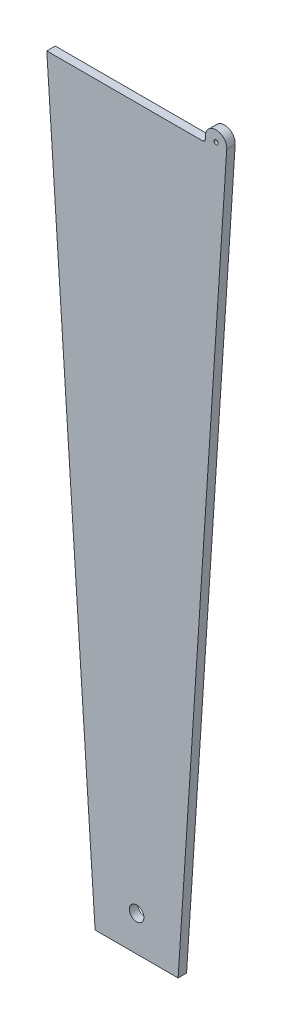
from build123d import *

# Parameters (mm, degrees)
EXTRUDE1_DEPTH     = 1.56
SKETCH2_R          = 1.3462
CUT_EXTRUDE2_DEPTH = 2.56
EXTRUDE2_DEPTH     = 1.56
FILLET1_R          = 0.5
SKETCH5_R          = 0.396875
EXTRUDE3_DEPTH     = 2.56


with BuildPart() as part:
    # Sketch1 → Extrude1 (new body)
    with BuildSketch(Plane.XY):
        Polygon((-7.655500537, 35), (7.655500537, 35), (16.56941148, 171), (-16.56941148, 171), align=None)
    extrude(amount=EXTRUDE1_DEPTH)

    # Sketch2 → Cut-Extrude2 (cut, through all)
    with BuildSketch(Plane(origin=(2.513247729, -24.95744912, 1.56), x_dir=(1, 0, 0), z_dir=(0, 0, 1))):
        with Locations((-2.513247729, 66.45744912)):
            Circle(SKETCH2_R)
    extrude(amount=-CUT_EXTRUDE2_DEPTH, mode=Mode.SUBTRACT)

    # Sketch4 → Extrude2 (add)
    with BuildSketch(Plane(origin=(0, 0, 0), x_dir=(-1, 0, 0), z_dir=(0, 0, -1))):
        with BuildLine():
            Line((-16.56941148, 171), (-16.628059301, 171.894792828))
            ThreePointArc((-16.628059301, 171.894792828), (-14.720969619, 173.99894204), (-12.68034522, 172.024027605))
            Line((-12.68034522, 172.024027605), (-12.68034522, 171))
            Line((-12.68034522, 171), (-16.56941148, 171))
        make_face()
    extrude(amount=-EXTRUDE2_DEPTH)

    # Fillet1
    fillet1_edges = [part.edges().sort_by_distance(p)[0] for p in [
        (12.68034522, 171, 0.78),
    ]]
    fillet(fillet1_edges, radius=FILLET1_R)

    # Sketch5 → Extrude3 (cut, through all)
    with BuildSketch(Plane.XY.offset(1.56)):
        with Locations((14.656317615, 172.024027605)):
            Circle(SKETCH5_R)
    extrude(amount=-EXTRUDE3_DEPTH, mode=Mode.SUBTRACT)


solid = part.part
